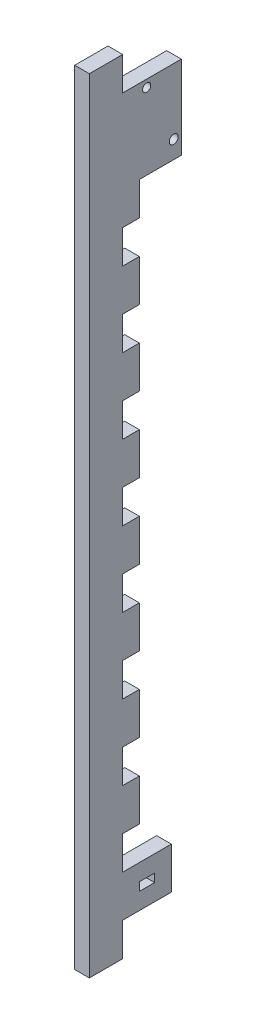
from build123d import *

# Parameters (mm, degrees)
BOSS_EXTRUDE1_DEPTH = 5.588
SKETCH2_W           = 22.3499934
SKETCH2_H           = 31.75
SKETCH2_R           = 1.55
SKETCH2_R_2         = 1.7
BOSS_EXTRUDE2_DEPTH = 5.588


with BuildPart() as part:
    # Sketch1 → Boss-Extrude1 (new body)
    with BuildSketch(Plane(origin=(0, 0, 0), x_dir=(0, 0, -1), z_dir=(1, 0, 0))):
        Polygon((3.175, 120.65), (9.525, 120.65), (9.525, 136.525), (3.175, 136.525), (3.175, 149.225), (-9.525, 149.225), (-9.525, -149.225), (3.175, -149.225), (3.175, -136.525), (9.525, -136.525), (9.525, -120.65), (3.175, -120.65), (3.175, -107.95), (9.525, -107.95), (9.525, -92.075), (3.175, -92.075), (3.175, -79.375), (9.525, -79.375), (9.525, -63.5), (3.175, -63.5), (3.175, -50.8), (9.525, -50.8), (9.525, -34.925), (3.175, -34.925), (3.175, -22.225), (9.525, -22.225), (9.525, -6.35), (3.175, -6.35), (3.175, 6.35), (9.525, 6.35), (9.525, 22.225), (3.175, 22.225), (3.175, 34.925), (9.525, 34.925), (9.525, 50.8), (3.175, 50.8), (3.175, 63.5), (9.525, 63.5), (9.525, 79.375), (3.175, 79.375), (3.175, 92.075), (9.525, 92.075), (9.525, 107.95), (3.175, 107.95), align=None)
    extrude(amount=BOSS_EXTRUDE1_DEPTH)

    # Sketch2 → Boss-Extrude2 (add)
    with BuildSketch(Plane(origin=(5.588, 0, 0), x_dir=(0, 0, -1), z_dir=(1, 0, 0))):
        Polygon((21.717, -120.65), (9.525, -120.65), (9.525, -127), (15.367, -127), (15.367, -130.175), (9.525, -130.175), (9.525, -136.525), (21.717, -136.525), align=None)
        with Locations((14.3499967, 120.65)):
            Rectangle(SKETCH2_W, SKETCH2_H)
        with Locations((12.3249992, 133.7250056)):
            Circle(SKETCH2_R, mode=Mode.SUBTRACT)
        with Locations((22.6249992, 111.5250056)):
            Circle(SKETCH2_R_2, mode=Mode.SUBTRACT)
    extrude(amount=-BOSS_EXTRUDE2_DEPTH)


solid = part.part
